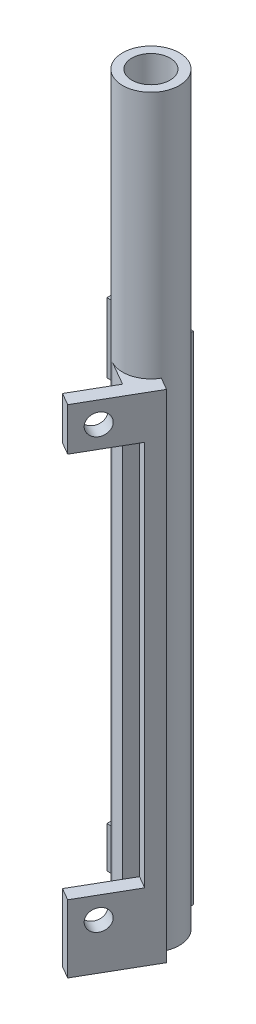
from build123d import *

# Parameters (mm, degrees)
SKETCH1_R           = 5.08
BOSS_EXTRUDE1_DEPTH = 133.35
SKETCH2_R           = 3.429
CUT_EXTRUDE1_DEPTH  = 134.35
BOSS_EXTRUDE2_DEPTH = 88.9
HOLE_CUTS_1_REACH   = 12.16
SKETCH4_R           = 1.905
HOLE_CUTS_2_REACH   = 17.219
SKETCH7_R           = 1.905
CUT_EXTRUDE7_REACH  = 135.35
SKETCH8_W           = 6.604
SKETCH8_H           = 4.572
SKETCH9_W           = 11.684
SKETCH9_H           = 88.9
CUT_EXTRUDE8_DEPTH  = 2.54
SKETCH10_W          = 11.684
SKETCH10_H          = 88.9
CUT_EXTRUDE9_DEPTH  = 2.54
SKETCH11_W          = 6.604
SKETCH11_H          = 88.9
CUT_EXTRUDE10_DEPTH = 0.508
SKETCH13_W          = 6.604
SKETCH13_H          = 88.9
CUT_EXTRUDE11_DEPTH = 0.508
SKETCH14_W          = 2.54
SKETCH14_H          = 88.9
BOSS_EXTRUDE3_DEPTH = 1.27
SKETCH15_W          = 2.54
SKETCH15_H          = 88.9
BOSS_EXTRUDE4_DEPTH = 1.27
SKETCH20_W          = 10.0965
SKETCH20_H          = 69.088
CUT_EXTRUDE13_DEPTH = 2.54
SKETCH21_W          = 10.0965
SKETCH21_H          = 69.088
CUT_EXTRUDE14_DEPTH = 2.54


with BuildPart() as part:
    # Sketch1 → Boss-Extrude1 (new body)
    with BuildSketch(Plane(origin=(0, 0, 0), x_dir=(1, 0, 0), z_dir=(0, 1, 0))):
        Circle(SKETCH1_R)
    extrude(amount=BOSS_EXTRUDE1_DEPTH)

    # Sketch2 → Cut-Extrude1 (cut, through all)
    with BuildSketch(Plane.XZ):
        Circle(SKETCH2_R)
    extrude(amount=-CUT_EXTRUDE1_DEPTH, mode=Mode.SUBTRACT)

    # Sketch3 → Boss-Extrude2 (add)
    with BuildSketch(Plane.XZ):
        with BuildLine():
            Line((-1.442590949, 12.658640818), (-5.842, 10.118640818))
            Line((-5.842, 10.118640818), (-2.54, 4.399409051))
            ThreePointArc((-2.54, 4.399409051), (2.96960111, -1.7145), (-5.08, 0))
            Line((-5.08, 0), (-11.684, 0))
            Line((-11.684, 0), (-11.684, -5.08))
            Line((-11.684, -5.08), (-11.684, -10.16))
            Line((-11.684, -10.16), (0, -10.16))
            Line((0, -10.16), (0, -5.08))
            ThreePointArc((0, -5.08), (4.399409051, -2.54), (4.399409051, 2.54))
            Line((4.399409051, 2.54), (8.798818102, 5.08))
            Line((8.798818102, 5.08), (2.956818102, 15.198640818))
            Line((2.956818102, 15.198640818), (-1.442590949, 12.658640818))
        make_face()
    extrude(amount=-BOSS_EXTRUDE2_DEPTH)

    # Sketch4 → Hole Cuts 1 (cut, up to next)
    with BuildSketch(Plane.XY, mode=Mode.PRIVATE) as hole_cuts_1_sk1:
        with Locations((-8.89, 80.01)):
            Circle(SKETCH4_R)
    hole_cuts_1_tool1 = extrude(hole_cuts_1_sk1.sketch, amount=-HOLE_CUTS_1_REACH, mode=Mode.PRIVATE) & part.part
    add(hole_cuts_1_tool1.solids().sort_by_distance((-8.89, 80.01, 0))[0], mode=Mode.SUBTRACT)
    # Sketch4 → Hole Cuts 1 (cut, up to next)
    with BuildSketch(Plane.XY, mode=Mode.PRIVATE) as hole_cuts_1_sk2:
        with Locations((-8.89, 3.81)):
            Circle(SKETCH4_R)
    hole_cuts_1_tool2 = extrude(hole_cuts_1_sk2.sketch, amount=-HOLE_CUTS_1_REACH, mode=Mode.PRIVATE) & part.part
    add(hole_cuts_1_tool2.solids().sort_by_distance((-8.89, 3.81, 0))[0], mode=Mode.SUBTRACT)

    # Sketch7 → Hole Cuts 2 (cut, up to next)
    with BuildSketch(Plane(origin=(0, 0, 0), x_dir=(0.5, 0, -0.866025404), z_dir=(0.866025404, 0, 0.5)), mode=Mode.PRIVATE) as hole_cuts_2_sk1:
        with Locations((-8.89, 85.09)):
            Circle(SKETCH7_R)
    hole_cuts_2_tool1 = extrude(hole_cuts_2_sk1.sketch, amount=HOLE_CUTS_2_REACH, mode=Mode.PRIVATE) & part.part
    add(hole_cuts_2_tool1.solids().sort_by_distance((-4.445, 85.09, 7.698966))[0], mode=Mode.SUBTRACT)
    # Sketch7 → Hole Cuts 2 (cut, up to next)
    with BuildSketch(Plane(origin=(0, 0, 0), x_dir=(0.5, 0, -0.866025404), z_dir=(0.866025404, 0, 0.5)), mode=Mode.PRIVATE) as hole_cuts_2_sk2:
        with Locations((-8.89, 8.255)):
            Circle(SKETCH7_R)
    hole_cuts_2_tool2 = extrude(hole_cuts_2_sk2.sketch, amount=HOLE_CUTS_2_REACH, mode=Mode.PRIVATE) & part.part
    add(hole_cuts_2_tool2.solids().sort_by_distance((-4.445, 8.255, 7.698966))[0], mode=Mode.SUBTRACT)

    # Sketch8 → Cut-Extrude7 (cut, up to next)
    with BuildSketch(Plane.XZ, mode=Mode.PRIVATE) as cut_extrude7_sk1:
        Polygon((-5.842, 10.118640818), (-1.882531854, 12.404640818), (1.419468146, 6.685409051), (-2.54, 4.399409051), align=None)
    cut_extrude7_tool1 = extrude(cut_extrude7_sk1.sketch, amount=-CUT_EXTRUDE7_REACH, mode=Mode.PRIVATE) & part.part
    add(cut_extrude7_tool1.solids().sort_by_distance((-2.211266, 0, 8.402025))[0], mode=Mode.SUBTRACT)
    # Sketch8 → Cut-Extrude7 (cut, up to next)
    with BuildSketch(Plane.XZ, mode=Mode.PRIVATE) as cut_extrude7_sk2:
        with Locations((-8.382, -2.286)):
            Rectangle(SKETCH8_W, SKETCH8_H)
    cut_extrude7_tool2 = extrude(cut_extrude7_sk2.sketch, amount=-CUT_EXTRUDE7_REACH, mode=Mode.PRIVATE) & part.part
    add(cut_extrude7_tool2.solids().sort_by_distance((-8.382, 0, -2.286))[0], mode=Mode.SUBTRACT)

    # Sketch9 → Cut-Extrude8 (cut)
    with BuildSketch(Plane(origin=(0, 0, -10.16), x_dir=(-1, 0, 0), z_dir=(0, 0, -1))):
        with Locations((5.842, 44.45)):
            Rectangle(SKETCH9_W, SKETCH9_H)
    extrude(amount=-CUT_EXTRUDE8_DEPTH, mode=Mode.SUBTRACT)

    # Sketch10 → Cut-Extrude9 (cut)
    with BuildSketch(Plane(origin=(8.798818102, 0, 5.08), x_dir=(0.5, 0, -0.866025404), z_dir=(0.866025404, 0, 0.5))):
        with Locations((-5.842, 44.45)):
            Rectangle(SKETCH10_W, SKETCH10_H)
    extrude(amount=-CUT_EXTRUDE9_DEPTH, mode=Mode.SUBTRACT)

    # Sketch11 → Cut-Extrude10 (cut)
    with BuildSketch(Plane.XY.offset(-4.572)):
        with Locations((-8.382, 44.45)):
            Rectangle(SKETCH11_W, SKETCH11_H)
    extrude(amount=-CUT_EXTRUDE10_DEPTH, mode=Mode.SUBTRACT)

    # Sketch13 → Cut-Extrude11 (cut)
    with BuildSketch(Plane(origin=(3.959468146, 0, 2.286), x_dir=(-0.5, 0, 0.866025404), z_dir=(-0.866025404, 0, -0.5))):
        with Locations((8.382, 44.45)):
            Rectangle(SKETCH13_W, SKETCH13_H)
    extrude(amount=-CUT_EXTRUDE11_DEPTH, mode=Mode.SUBTRACT)

    # Sketch14 → Boss-Extrude3 (add)
    with BuildSketch(Plane(origin=(-5.842, 0, 10.118640818), x_dir=(0.866025404, 0, 0.5), z_dir=(-0.5, 0, 0.866025404))):
        with Locations((6.35, 44.45)):
            Rectangle(SKETCH14_W, SKETCH14_H)
    extrude(amount=BOSS_EXTRUDE3_DEPTH)

    # Sketch15 → Boss-Extrude4 (add)
    with BuildSketch(Plane.ZY.offset(11.684)):
        with Locations((-6.35, 44.45)):
            Rectangle(SKETCH15_W, SKETCH15_H)
    extrude(amount=BOSS_EXTRUDE4_DEPTH)

    # Sketch20 → Cut-Extrude13 (cut)
    with BuildSketch(Plane.XY.offset(-5.08)):
        with Locations((-7.90575, 41.91)):
            Rectangle(SKETCH20_W, SKETCH20_H)
    extrude(amount=-CUT_EXTRUDE13_DEPTH, mode=Mode.SUBTRACT)

    # Sketch21 → Cut-Extrude14 (cut)
    with BuildSketch(Plane(origin=(6.599113577, 0, 3.81), x_dir=(0.5, 0, -0.866025404), z_dir=(0.866025404, 0, 0.5))):
        with Locations((-7.90575, 46.6725)):
            Rectangle(SKETCH21_W, SKETCH21_H)
    extrude(amount=-CUT_EXTRUDE14_DEPTH, mode=Mode.SUBTRACT)


solid = part.part
